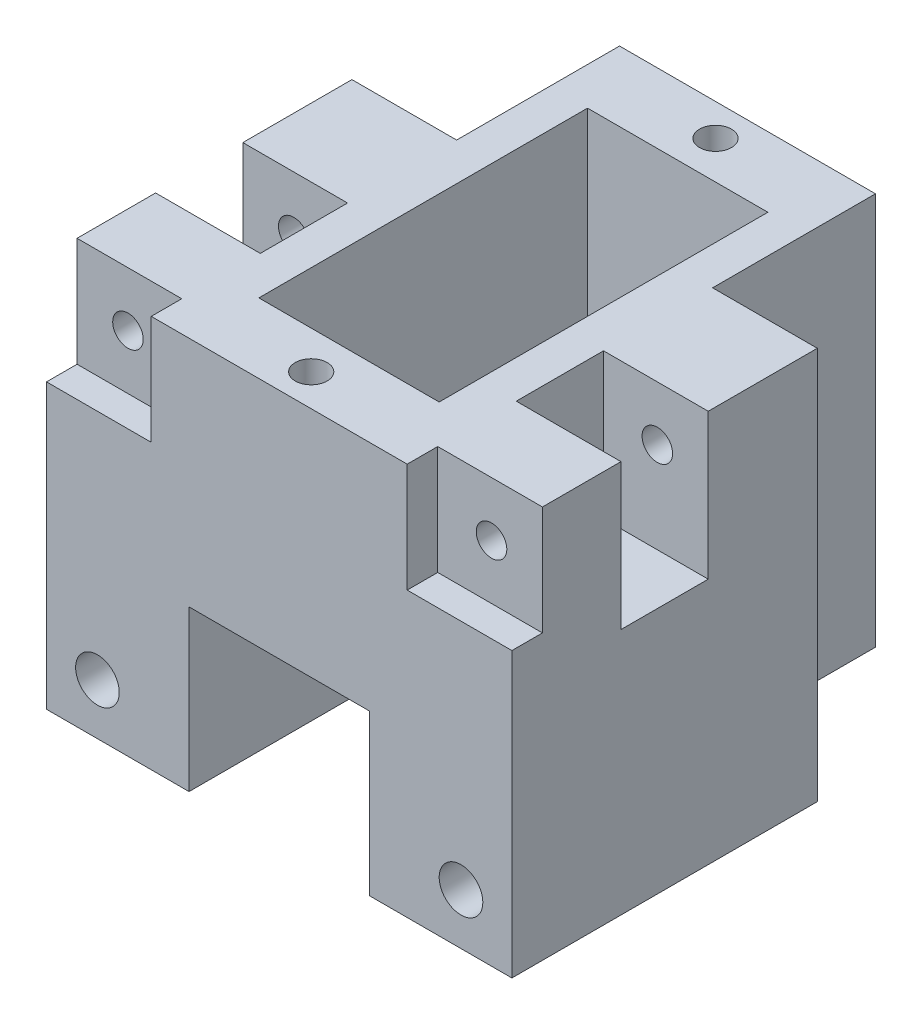
from build123d import *

# Parameters (mm, degrees)
BOSS_EXTRUDE2_START        = 2
SKETCH1_W                  = 12.4
SKETCH1_H                  = 22.6
BOSS_EXTRUDE2_DEPTH        = 27
SKETCH2_W                  = 7.2
SKETCH2_H                  = 2.1
CUT_EXTRUDE1_DEPTH         = 7.5
SKETCH3_W                  = 12.4
SKETCH3_H                  = 11
CUT_EXTRUDE2_DEPTH         = 124.829883308
CUT_EXTRUDE2_DEPTH_BACK    = 124.829883308
SKETCH2_3_W                = 7.2
SKETCH2_3_H                = 6
CUT_EXTRUDE3_DEPTH         = 10
SKETCH7_R                  = 1.05
SKETCH7_R_2                = 1.5
CUT_EXTRUDE9_DEPTH         = 124.829883308
SKETCH1_8_R                = 1.5
CUT_EXTRUDE12_DEPTH        = 12
F_2_2_2_2_DIAMETER_HOLE1_D = 2.2


with BuildPart() as part:
    # Sketch1 → Boss-Extrude2 (new body)
    with BuildSketch(Plane(origin=(0, 0, 0), x_dir=(1, 0, 0), z_dir=(0, 1, 0)).offset(BOSS_EXTRUDE2_START)):
        Polygon((84, 98), (84, 77), (116, 77), (116, 98), (108.8, 98), (108.8, 109.2), (91.2, 109.2), (91.2, 98), align=None)
        with Locations((100, 93.1)):
            Rectangle(SKETCH1_W, SKETCH1_H, mode=Mode.SUBTRACT)
    extrude(amount=BOSS_EXTRUDE2_DEPTH)

    # Sketch2 → Cut-Extrude1 (cut)
    with BuildSketch(Plane(origin=(0, 29, 0), x_dir=(1, 0, 0), z_dir=(0, 1, 0))):
        with Locations((112.4, 78.05)):
            Rectangle(SKETCH2_W, SKETCH2_H)
        Polygon((84, 79.1), (84, 78.995319666), (84, 77), (91.2, 77), (91.2, 79.1), align=None)
    extrude(amount=-CUT_EXTRUDE1_DEPTH, mode=Mode.SUBTRACT)

    # Sketch3 → Cut-Extrude2 (cut, two sides)
    with BuildSketch(Plane.XY.offset(-77)) as cut_extrude2_sk:
        with Locations((100, 7.5)):
            Rectangle(SKETCH3_W, SKETCH3_H)
    extrude(amount=CUT_EXTRUDE2_DEPTH, mode=Mode.SUBTRACT)
    extrude(cut_extrude2_sk.sketch, amount=-CUT_EXTRUDE2_DEPTH_BACK, mode=Mode.SUBTRACT)

    # Sketch2_3 → Cut-Extrude3 (cut)
    with BuildSketch(Plane(origin=(0, 29, 0), x_dir=(1, 0, 0), z_dir=(0, 1, 0))):
        Polygon((108.8, 84.5), (116, 84.5), (116, 85.211636412), (116, 90.5), (108.8, 90.5), align=None)
        with Locations((87.6, 87.5)):
            Rectangle(SKETCH2_3_W, SKETCH2_3_H)
    extrude(amount=-CUT_EXTRUDE3_DEPTH, mode=Mode.SUBTRACT)

    # Sketch7 → Cut-Extrude9 (cut, through all)
    with BuildSketch(Plane.XY.offset(-77)):
        with Locations((87.5, 25.25)):
            Circle(SKETCH7_R)
        with Locations((112.5, 25.25)):
            Circle(SKETCH7_R)
        with Locations((87.5, 5.5)):
            Circle(SKETCH7_R_2)
        with Locations((112.5, 5.5)):
            Circle(SKETCH7_R_2)
    extrude(amount=-CUT_EXTRUDE9_DEPTH, mode=Mode.SUBTRACT)

    # Sketch1_8 → Cut-Extrude12 (cut)
    with BuildSketch(Plane(origin=(0, 0, 0), x_dir=(1, 0, 0), z_dir=(0, 1, 0))):
        with Locations(Location((109, 82, 0), (0, 0, 270))):
            Circle(SKETCH1_8_R)
        with Locations(Location((109, 93, 0), (0, 0, 270))):
            Circle(SKETCH1_8_R)
        with Locations(Location((91, 82, 0), (0, 0, 270))):
            Circle(SKETCH1_8_R)
        with Locations(Location((91, 93, 0), (0, 0, 270))):
            Circle(SKETCH1_8_R)
    extrude(amount=CUT_EXTRUDE12_DEPTH, mode=Mode.SUBTRACT)

    # Ø2.2 (2.2) Diameter Hole1 (through all)
    with Locations(Plane(origin=(0, 29, 0), x_dir=(1, 0, 0), z_dir=(0, 1, 0))):
        with Locations((100, 79.2), (100, 107)):
            Hole(F_2_2_2_2_DIAMETER_HOLE1_D / 2)


solid = part.part
